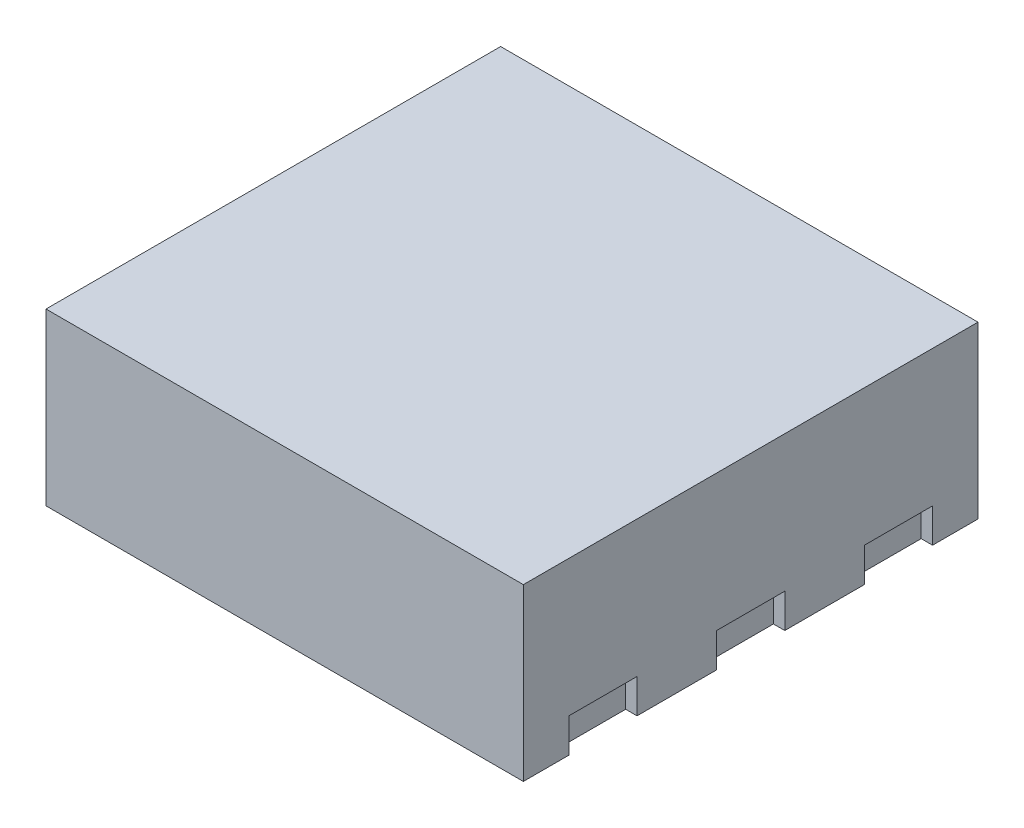
from build123d import *

# Parameters (mm, degrees)
SKETCH1_W           = 2.1
SKETCH1_H           = 2
BOSS_EXTRUDE1_DEPTH = 0.75
SKETCH2_W           = 0.3
SKETCH2_H           = 0.2
CUT_EXTRUDE1_DEPTH  = 0.05
SKETCH3_W           = 0.65
SKETCH3_H           = 1.35
CUT_EXTRUDE2_DEPTH  = 0.01


with BuildPart() as part:
    # Sketch1 → Boss-Extrude1 (new body)
    with BuildSketch(Plane(origin=(0, 0, 0), x_dir=(1, 0, 0), z_dir=(0, 1, 0))):
        Rectangle(SKETCH1_W, SKETCH1_H)
    extrude(amount=BOSS_EXTRUDE1_DEPTH)

    # Sketch2 → Cut-Extrude1 (cut)
    with BuildSketch(Plane(origin=(1.05, 0, 0), x_dir=(0, 0, -1), z_dir=(1, 0, 0))):
        with Locations((-0.65, 0.05)):
            Rectangle(SKETCH2_W, SKETCH2_H)
        with Locations((0, 0.05)):
            Rectangle(SKETCH2_W, SKETCH2_H)
        with Locations((0.65, 0.05)):
            Rectangle(SKETCH2_W, SKETCH2_H)
    cut_extrude1 = extrude(amount=-CUT_EXTRUDE1_DEPTH, mode=Mode.SUBTRACT)

    # Mirror1: Cut-Extrude1 across plane
    add(cut_extrude1.mirror(Plane(origin=(0, 0, 0), x_dir=(0, 0, 1), z_dir=(1, 0, 0))), mode=Mode.SUBTRACT)

    # Sketch3 → Cut-Extrude2 (cut)
    with BuildSketch(Plane.XZ):
        Rectangle(SKETCH3_W, SKETCH3_H)
    extrude(amount=-CUT_EXTRUDE2_DEPTH, mode=Mode.SUBTRACT)


solid = part.part
